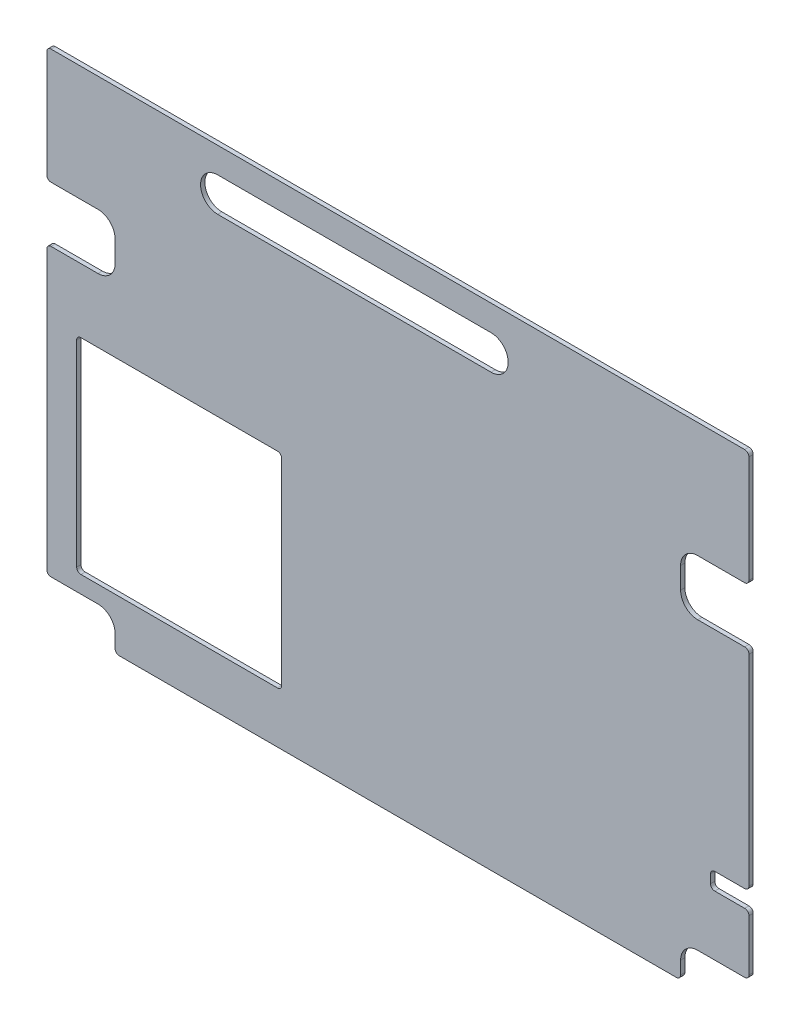
from build123d import *

# Parameters (mm, degrees)
SKETCH1_W           = 1043.686
SKETCH1_H           = 730.25
BOSS_EXTRUDE1_DEPTH = 6.35
SKETCH9_W           = 304.8
SKETCH9_H           = 304.8
CUT_EXTRUDE3_DEPTH  = 6.35
CUT_EXTRUDE4_DEPTH  = 6.35
FILLET1_R           = 6.35
CUT_EXTRUDE6_DEPTH  = 7.35


with BuildPart() as part:
    # Sketch1 → Boss-Extrude1 (new body)
    with BuildSketch(Plane.XY):
        with Locations((521.843, 365.125)):
            Rectangle(SKETCH1_W, SKETCH1_H)
    extrude(amount=BOSS_EXTRUDE1_DEPTH)

    # Sketch9 → Cut-Extrude3 (cut)
    with BuildSketch(Plane(origin=(0, 0, 0), x_dir=(-1, 0, 0), z_dir=(0, 0, -1))):
        with Locations((-196.85, 228.6)):
            Rectangle(SKETCH9_W, SKETCH9_H)
    extrude(amount=-CUT_EXTRUDE3_DEPTH, mode=Mode.SUBTRACT)

    # Sketch10 → Cut-Extrude4 (cut)
    with BuildSketch(Plane.XY.offset(6.35)):
        with BuildLine():
            Line((76.2, 50.8), (0, 50.8))
            Line((0, 50.8), (0, 0))
            Line((0, 0), (101.6, 0))
            Line((101.6, 0), (101.6, 25.4))
            ThreePointArc((101.6, 25.4), (94.160512242, 43.360512242), (76.2, 50.8))
        make_face()
        with BuildLine():
            Line((942.086, 25.4), (942.086, 0))
            Line((942.086, 0), (1043.686, 0))
            Line((1043.686, 0), (1043.686, 50.8))
            Line((1043.686, 50.8), (967.486, 50.8))
            ThreePointArc((967.486, 50.8), (949.525487758, 43.360512242), (942.086, 25.4))
        make_face()
        with BuildLine():
            Line((967.486, 558.8), (1043.686, 558.8))
            Line((1043.686, 558.8), (1043.686, 476.25))
            Line((1043.686, 476.25), (967.486, 476.25))
            ThreePointArc((967.486, 476.25), (949.525487758, 483.689487758), (942.086, 501.65))
            Line((942.086, 501.65), (942.086, 533.4))
            ThreePointArc((942.086, 533.4), (949.525487758, 551.360512242), (967.486, 558.8))
        make_face()
        with BuildLine():
            Line((76.2, 558.8), (0, 558.8))
            Line((0, 558.8), (0, 476.25))
            Line((0, 476.25), (76.2, 476.25))
            ThreePointArc((76.2, 476.25), (94.160512242, 483.689487758), (101.6, 501.65))
            Line((101.6, 501.65), (101.6, 533.4))
            ThreePointArc((101.6, 533.4), (94.160512242, 551.360512242), (76.2, 558.8))
        make_face()
        with BuildLine():
            Line((1043.686, 139.7), (1043.686, 165.1))
            Line((1043.686, 165.1), (992.886, 165.1))
            ThreePointArc((992.886, 165.1), (988.395871939, 163.240128061), (986.536, 158.75))
            Line((986.536, 158.75), (986.536, 146.05))
            ThreePointArc((986.536, 146.05), (988.395871939, 141.559871939), (992.886, 139.7))
            Line((992.886, 139.7), (1043.686, 139.7))
        make_face()
    extrude(amount=-CUT_EXTRUDE4_DEPTH, mode=Mode.SUBTRACT)

    # Fillet1
    fillet1_edges = [part.edges().sort_by_distance(p)[0] for p in [
        (349.25, 76.2, 3.175),
        (349.25, 381, 3.175),
        (44.45, 381, 3.175),
        (44.45, 76.2, 3.175),
        (1043.686, 558.8, 3.175),
        (1043.686, 476.25, 3.175),
        (1043.686, 50.8, 3.175),
        (942.086, 0, 3.175),
        (0, 476.25, 3.175),
        (0, 558.8, 3.175),
        (0, 730.25, 3.175),
        (1043.686, 730.25, 3.175),
        (1043.686, 139.7, 3.175),
        (1043.686, 165.1, 3.175),
        (101.6, 0, 3.175),
        (0, 50.8, 3.175),
    ]]
    fillet(fillet1_edges, radius=FILLET1_R)

    # Sketch14 → Cut-Extrude6 (cut, through all)
    with BuildSketch(Plane(origin=(0, 0, 0), x_dir=(-1, 0, 0), z_dir=(0, 0, -1))):
        with BuildLine():
            Line((-660.4, 692.15), (-254, 692.15))
            ThreePointArc((-254, 692.15), (-228.6, 666.75), (-254, 641.35))
            Line((-254, 641.35), (-660.4, 641.35))
            ThreePointArc((-660.4, 641.35), (-685.8, 666.75), (-660.4, 692.15))
        make_face()
    extrude(amount=-CUT_EXTRUDE6_DEPTH, mode=Mode.SUBTRACT)


solid = part.part
